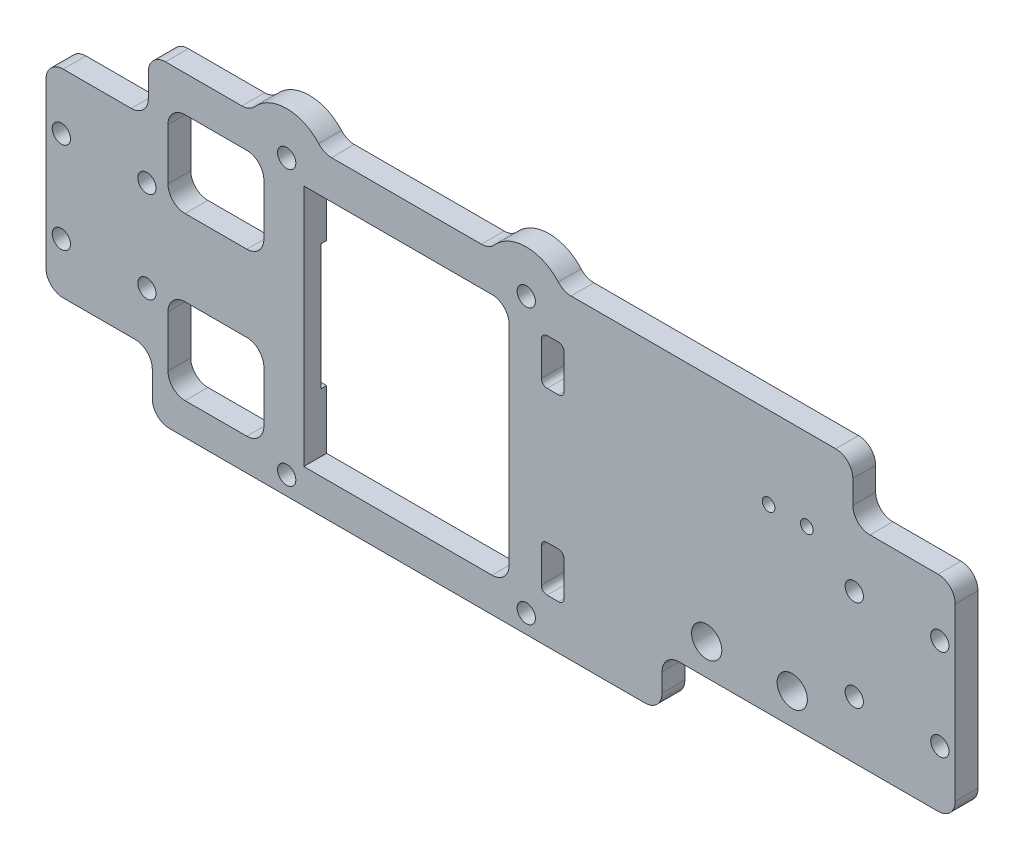
from build123d import *

# Parameters (mm, degrees)
SKETCH1_W                = 200
SKETCH1_H                = 135.733442348
SKETCH1_W_2              = 36
SKETCH1_H_2              = 42.1
BOSS_EXTRUDE1_DEPTH      = 4
M3_CLEARANCE_HOLE3_D     = 3.2
M3_CLEARANCE_HOLE3_DEPTH = 20
M3_CLEARANCE_HOLE3_TIP   = 0.96137699
M3_CLEARANCE_HOLE2_D     = 3.6
M3_CLEARANCE_HOLE2_DEPTH = 20
M3_CLEARANCE_HOLE2_TIP   = 1.081549114
ESBO_O16_W               = 16.814344546
ESBO_O16_H               = 12
RESSALTO_EXTRUS_O1_DEPTH = 4
FILETE2_R                = 1.5
ESBO_O10_W               = 1
ESBO_O10_H               = 4.177581522
CORTE_EXTRUS_O3_DEPTH    = 1
M5_CLEARANCE_HOLE1_D     = 5.3
ESBO_O13_OUTSIDE_W       = 250.348
ESBO_O13_OUTSIDE_H       = 186.081
CORTE_EXTRUS_O4_DEPTH    = 5
FILETE3_R                = 3
FILETE4_R                = 1.5
M3_CLEARANCE_HOLE5_D     = 3.2
M2_CLEARANCE_HOLE1_D     = 2.2
ESBO_O20_R               = 1.5
CORTE_EXTRUS_O5_DEPTH    = 10
M3_CLEARANCE_HOLE1_D     = 3.2
SKETCH53_W               = 36
SKETCH53_H               = 0.25
CUT_EXTRUDE12_DEPTH      = 10
SKETCH54_W               = 4
SKETCH54_H               = 8
CUT_EXTRUDE13_DEPTH      = 10
FILLET1_R                = 1
CUT_EXTRUDE14_DEPTH      = 10
SKETCH56_W               = 3.64947879
SKETCH56_H               = 22
CUT_EXTRUDE15_DEPTH      = 1
SKETCH57_R               = 2.05212086
CUT_EXTRUDE16_DEPTH      = 4
CUT_EXTRUDE17_DEPTH      = 4
SKETCH59_W               = 155.037210428
SKETCH59_H               = 70.505099338
CUT_EXTRUDE18_DEPTH      = 4
FILLET2_R                = 3
SKETCH60_W               = 18.240143326
SKETCH60_H               = 4.433631385
SKETCH60_H_2             = 1.833631385
BOSS_EXTRUDE2_DEPTH      = 4
FILLET3_R                = 3
FILETE5_R                = 3
SKETCH61_W               = 53.971209307
SKETCH61_H               = 36.749071907
SKETCH61_W_2             = 19.857566902
SKETCH61_H_2             = 38.368874149
CUT_EXTRUDE19_DEPTH      = 4
FILLET4_R                = 3
BOSS_EXTRUDE3_DEPTH      = 4
FILLET5_R                = 3


with BuildPart() as part:
    # Sketch1 → Boss-Extrude1 (new body)
    with BuildSketch(Plane.XY):
        with Locations((99.001292919, 88.116758365)):
            Rectangle(SKETCH1_W, SKETCH1_H)
        with BuildLine():
            Line((40.686948373, 33.880216301), (40.686948373, 79.280216301))
            ThreePointArc((40.686948373, 79.280216301), (41.272734811, 80.694429863), (42.686948373, 81.280216301))
            Line((42.686948373, 81.280216301), (55.501292919, 81.280216301))
            ThreePointArc((55.501292919, 81.280216301), (56.915506481, 80.694429863), (57.501292919, 79.280216301))
            Line((57.501292919, 79.280216301), (57.501292919, 33.880216301))
            ThreePointArc((57.501292919, 33.880216301), (56.915506481, 32.466002739), (55.501292919, 31.880216301))
            Line((55.501292919, 31.880216301), (42.686948373, 31.880216301))
            ThreePointArc((42.686948373, 31.880216301), (41.272734811, 32.466002739), (40.686948373, 33.880216301))
        make_face(mode=Mode.SUBTRACT)
        with Locations((82.501292919, 56.580216301)):
            Rectangle(SKETCH1_W_2, SKETCH1_H_2, mode=Mode.SUBTRACT)
    extrude(amount=BOSS_EXTRUDE1_DEPTH)

    # M3 Clearance Hole3
    with Locations(Plane(origin=(-2.189579835, 26.715952277, 4), x_dir=(1, 0, 0), z_dir=(0, 0, 1))):
        with Locations((63.690872753, 53.914264024), (63.690872753, 5.814264024), (105.690872753, 5.814264024), (105.690872753, 53.914264024)):
            Hole(M3_CLEARANCE_HOLE3_D / 2, depth=M3_CLEARANCE_HOLE3_DEPTH)
            with Locations((0, 0, -(M3_CLEARANCE_HOLE3_DEPTH + M3_CLEARANCE_HOLE3_TIP / 2))):  # 118° drill point
                Cone(0, M3_CLEARANCE_HOLE3_D / 2, M3_CLEARANCE_HOLE3_TIP, mode=Mode.SUBTRACT)

    # M3 Clearance Hole2
    with Locations(Plane.XY.offset(4)):
        with Locations((52.751292919, 139.766758365), (145.251292919, 139.766758365), (145.251292919, 86.466758365), (52.751292919, 86.466758365)):
            Hole(M3_CLEARANCE_HOLE2_D / 2, depth=M3_CLEARANCE_HOLE2_DEPTH)
            with Locations((0, 0, -(M3_CLEARANCE_HOLE2_DEPTH + M3_CLEARANCE_HOLE2_TIP / 2))):  # 118° drill point
                Cone(0, M3_CLEARANCE_HOLE2_D / 2, M3_CLEARANCE_HOLE2_TIP, mode=Mode.SUBTRACT)

    # Esbo_o16 → Ressalto-extrus_o1 (add)
    with BuildSketch(Plane.XY.offset(4)):
        with Locations((49.094120646, 56.580216301)):
            Rectangle(ESBO_O16_W, ESBO_O16_H)
    extrude(amount=-RESSALTO_EXTRUS_O1_DEPTH)

    # Filete2
    filete2_edges = [part.edges().sort_by_distance(p)[0] for p in [
        (-0.998707081, 155.983479539, 2),
        (199.001292919, 155.983479539, 2),
        (199.001292919, 20.250037191, 2),
        (-0.998707081, 20.250037191, 2),
    ]]
    fillet(filete2_edges, radius=FILETE2_R)

    # Esbo_o10 → Corte-extrus_o3 (cut)
    with BuildSketch(Plane(origin=(0, 0, 0), x_dir=(-1, 0, 0), z_dir=(0, 0, -1))):
        with Locations((-99.001292919, 155.983479539)):
            Rectangle(ESBO_O10_W, ESBO_O10_H)
    extrude(amount=-CORTE_EXTRUS_O3_DEPTH, mode=Mode.SUBTRACT)

    # M5 Clearance Hole1 (through all)
    with Locations(Plane(origin=(0, 0, 0), x_dir=(-1, 0, 0), z_dir=(0, 0, -1))):
        with Locations((-150.127125859, 44.005395411), (-135.127125859, 44.005395411)):
            Hole(M5_CLEARANCE_HOLE1_D / 2)

    # Esbo_o13 outside → Corte-extrus_o4 (cut, through all)
    with BuildSketch(Plane(origin=(0, 0, 0), x_dir=(-1, 0, 0), z_dir=(0, 0, -1))):
        with Locations((-99.001, 88.1165)):
            Rectangle(ESBO_O13_OUTSIDE_W, ESBO_O13_OUTSIDE_H)
        with BuildLine():
            Line((-179.691739081, 74.523312849), (-160.749455784, 74.523312849))
            Line((-160.749455784, 74.523312849), (-160.749455784, 105.180216331))
            ThreePointArc((-160.749455784, 105.180216331), (-168.249455784, 112.680216331), (-160.749455784, 120.180216331))
            Line((-160.749455784, 120.180216331), (-150.438183024, 134.349547733))
            ThreePointArc((-150.438183024, 134.349547733), (-151.315529823, 144.179810684), (-141.691903083, 146.368329693))
            Line((-141.691903083, 146.368329693), (-56.310682755, 146.368329693))
            ThreePointArc((-56.310682755, 146.368329693), (-46.687056014, 144.179810684), (-47.564402813, 134.349547733))
            Line((-47.564402813, 134.349547733), (-37.253130053, 120.180216331))
            ThreePointArc((-37.253130053, 120.180216331), (-29.753130053, 112.680216331), (-37.253130053, 105.180216331))
            Line((-37.253130053, 105.180216331), (-37.253130053, 74.523312849))
            Line((-37.253130053, 74.523312849), (-18.310846757, 74.523312849))
            Line((-18.310846757, 74.523312849), (-18.310846757, 29.275457367))
            Line((-18.310846757, 29.275457367), (-179.691739081, 29.275457367))
            Line((-179.691739081, 29.275457367), (-179.691739081, 74.523312849))
        make_face(mode=Mode.SUBTRACT)
    extrude(amount=-CORTE_EXTRUS_O4_DEPTH, mode=Mode.SUBTRACT)

    # Filete3
    filete3_edges = [part.edges().sort_by_distance(p)[0] for p in [
        (37.253130053, 74.523312849, 2),
        (18.310846757, 74.523312849, 2),
        (18.310846757, 29.275457367, 2),
        (179.691739081, 29.275457367, 2),
        (179.691739081, 74.523312849, 2),
        (160.749455784, 74.523312849, 2),
    ]]
    fillet(filete3_edges, radius=FILETE3_R)

    # Filete4
    filete4_edges = [part.edges().sort_by_distance(p)[0] for p in [
        (37.253130053, 105.180216331, 2),
        (160.749455784, 105.180216331, 2),
        (160.749455784, 120.180216331, 2),
        (150.438183024, 134.349547733, 2),
        (141.691903083, 146.368329693, 2),
        (56.310682755, 146.368329693, 2),
        (47.564402813, 134.349547733, 2),
        (37.253130053, 120.180216331, 2),
    ]]
    fillet(filete4_edges, radius=FILETE4_R)

    # M3 Clearance Hole5 (through all)
    with Locations(Plane(origin=(0, 0, 0), x_dir=(-1, 0, 0), z_dir=(0, 0, -1))):
        with Locations((-36.749455784, 112.680216331), (-160.749455784, 112.680216331)):
            Hole(M3_CLEARANCE_HOLE5_D / 2)

    # M2 Clearance Hole1 (through all)
    with Locations(Plane(origin=(0, 0, 0), x_dir=(-1, 0, 0), z_dir=(0, 0, -1))):
        with Locations((-145.982603611, 70.250037191), (-152.682603611, 70.250037191)):
            Hole(M2_CLEARANCE_HOLE1_D / 2)

    # Esbo_o20 → Corte-extrus_o5 (cut)
    with BuildSketch(Plane.XY.offset(4)):
        with Locations((99.001292919, 113.116758365)):
            Circle(ESBO_O20_R)
        with Locations((99.001292919, 119.116758365)):
            Circle(ESBO_O20_R)
        with Locations((95.144567261, 117.713025024)):
            Circle(ESBO_O20_R)
        with Locations((93.092446401, 114.158647431)):
            Circle(ESBO_O20_R)
        with Locations((93.805140496, 110.116758365)):
            Circle(ESBO_O20_R)
        with Locations((96.949172059, 107.478602641)):
            Circle(ESBO_O20_R)
        with Locations((101.053413779, 107.478602641)):
            Circle(ESBO_O20_R)
        with Locations((104.197445341, 110.116758365)):
            Circle(ESBO_O20_R)
        with Locations((104.910139437, 114.158647431)):
            Circle(ESBO_O20_R)
        with Locations((102.858018577, 117.713025024)):
            Circle(ESBO_O20_R)
        with Locations((99.001292919, 125.116758365)):
            Circle(ESBO_O20_R)
        with Locations((99.001292919, 131.116758365)):
            Circle(ESBO_O20_R)
        with Locations((99.001292919, 137.116758365)):
            Circle(ESBO_O20_R)
        with Locations((94.897051199, 124.393069815)):
            Circle(ESBO_O20_R)
        with Locations((91.287841602, 122.309291683)):
            Circle(ESBO_O20_R)
        with Locations((88.608988073, 119.116758365)):
            Circle(ESBO_O20_R)
        with Locations((87.183599882, 115.200536497)):
            Circle(ESBO_O20_R)
        with Locations((87.183599882, 111.032980233)):
            Circle(ESBO_O20_R)
        with Locations((88.608988073, 107.116758365)):
            Circle(ESBO_O20_R)
        with Locations((91.287841602, 103.924225048)):
            Circle(ESBO_O20_R)
        with Locations((94.897051199, 101.840446916)):
            Circle(ESBO_O20_R)
        with Locations((99.001292919, 101.116758365)):
            Circle(ESBO_O20_R)
        with Locations((103.105534639, 101.840446916)):
            Circle(ESBO_O20_R)
        with Locations((106.714744235, 103.924225048)):
            Circle(ESBO_O20_R)
        with Locations((109.393597764, 107.116758365)):
            Circle(ESBO_O20_R)
        with Locations((110.818985955, 111.032980233)):
            Circle(ESBO_O20_R)
        with Locations((110.818985955, 115.200536497)):
            Circle(ESBO_O20_R)
        with Locations((109.393597764, 119.116758365)):
            Circle(ESBO_O20_R)
        with Locations((106.714744235, 122.309291683)):
            Circle(ESBO_O20_R)
        with Locations((103.105534639, 124.393069815)):
            Circle(ESBO_O20_R)
        with Locations((102.743703353, 130.723415178)):
            Circle(ESBO_O20_R)
        with Locations((106.322552494, 129.560576603)):
            Circle(ESBO_O20_R)
        with Locations((109.58142746, 127.679064264)):
            Circle(ESBO_O20_R)
        with Locations((112.377899777, 125.16110928)):
            Circle(ESBO_O20_R)
        with Locations((114.589750187, 122.116758365)):
            Circle(ESBO_O20_R)
        with Locations((116.120310212, 118.679064264)):
            Circle(ESBO_O20_R)
        with Locations((116.902687035, 114.998270704)):
            Circle(ESBO_O20_R)
        with Locations((116.902687035, 111.235246026)):
            Circle(ESBO_O20_R)
        with Locations((116.120310212, 107.554452467)):
            Circle(ESBO_O20_R)
        with Locations((114.589750187, 104.116758365)):
            Circle(ESBO_O20_R)
        with Locations((112.377899777, 101.072407451)):
            Circle(ESBO_O20_R)
        with Locations((109.58142746, 98.554452467)):
            Circle(ESBO_O20_R)
        with Locations((106.322552494, 96.672940128)):
            Circle(ESBO_O20_R)
        with Locations((102.743703353, 95.510101552)):
            Circle(ESBO_O20_R)
        with Locations((99.001292919, 95.116758365)):
            Circle(ESBO_O20_R)
        with Locations((95.258882484, 95.510101552)):
            Circle(ESBO_O20_R)
        with Locations((91.680033343, 96.672940128)):
            Circle(ESBO_O20_R)
        with Locations((88.421158377, 98.554452467)):
            Circle(ESBO_O20_R)
        with Locations((85.62468606, 101.072407451)):
            Circle(ESBO_O20_R)
        with Locations((83.412835651, 104.116758365)):
            Circle(ESBO_O20_R)
        with Locations((81.882275625, 107.554452467)):
            Circle(ESBO_O20_R)
        with Locations((81.099898802, 111.235246026)):
            Circle(ESBO_O20_R)
        with Locations((81.099898802, 114.998270704)):
            Circle(ESBO_O20_R)
        with Locations((81.882275625, 118.679064264)):
            Circle(ESBO_O20_R)
        with Locations((83.412835651, 122.116758365)):
            Circle(ESBO_O20_R)
        with Locations((85.62468606, 125.16110928)):
            Circle(ESBO_O20_R)
        with Locations((88.421158377, 127.679064264)):
            Circle(ESBO_O20_R)
        with Locations((91.680033343, 129.560576603)):
            Circle(ESBO_O20_R)
        with Locations((95.258882484, 130.723415178)):
            Circle(ESBO_O20_R)
        with Locations((103.411281346, 136.708112758)):
            Circle(ESBO_O20_R)
        with Locations((107.671092907, 135.496091871)):
            Circle(ESBO_O20_R)
        with Locations((111.635664828, 133.521969623)):
            Circle(ESBO_O20_R)
        with Locations((115.169988366, 130.852972379)):
            Circle(ESBO_O20_R)
        with Locations((118.153706373, 127.579989638)):
            Circle(ESBO_O20_R)
        with Locations((120.485211911, 123.814478904)):
            Circle(ESBO_O20_R)
        with Locations((122.085108355, 119.684670127)):
            Circle(ESBO_O20_R)
        with Locations((122.89891315, 115.331198992)):
            Circle(ESBO_O20_R)
        with Locations((122.89891315, 110.902317738)):
            Circle(ESBO_O20_R)
        with Locations((122.085108355, 106.548846604)):
            Circle(ESBO_O20_R)
        with Locations((120.485211911, 102.419037827)):
            Circle(ESBO_O20_R)
        with Locations((118.153706373, 98.653527092)):
            Circle(ESBO_O20_R)
        with Locations((115.169988366, 95.380544352)):
            Circle(ESBO_O20_R)
        with Locations((111.635664828, 92.711547108)):
            Circle(ESBO_O20_R)
        with Locations((107.671092907, 90.73742486)):
            Circle(ESBO_O20_R)
        with Locations((103.411281346, 89.525403973)):
            Circle(ESBO_O20_R)
        with Locations((99.001292919, 89.116758365)):
            Circle(ESBO_O20_R)
        with Locations((94.591304491, 89.525403973)):
            Circle(ESBO_O20_R)
        with Locations((90.33149293, 90.73742486)):
            Circle(ESBO_O20_R)
        with Locations((86.36692101, 92.711547108)):
            Circle(ESBO_O20_R)
        with Locations((82.832597471, 95.380544352)):
            Circle(ESBO_O20_R)
        with Locations((79.848879464, 98.653527092)):
            Circle(ESBO_O20_R)
        with Locations((77.517373926, 102.419037827)):
            Circle(ESBO_O20_R)
        with Locations((75.917477482, 106.548846604)):
            Circle(ESBO_O20_R)
        with Locations((75.103672688, 110.902317738)):
            Circle(ESBO_O20_R)
        with Locations((75.103672688, 115.331198992)):
            Circle(ESBO_O20_R)
        with Locations((75.917477482, 119.684670127)):
            Circle(ESBO_O20_R)
        with Locations((77.517373926, 123.814478904)):
            Circle(ESBO_O20_R)
        with Locations((79.848879464, 127.579989638)):
            Circle(ESBO_O20_R)
        with Locations((82.832597471, 130.852972379)):
            Circle(ESBO_O20_R)
        with Locations((86.36692101, 133.521969623)):
            Circle(ESBO_O20_R)
        with Locations((90.33149293, 135.496091871)):
            Circle(ESBO_O20_R)
        with Locations((94.591304491, 136.708112758)):
            Circle(ESBO_O20_R)
    extrude(amount=-CORTE_EXTRUS_O5_DEPTH, mode=Mode.SUBTRACT)

    # M3 Clearance Hole1 (through all)
    with Locations(Plane(origin=(0, 0, 0), x_dir=(-1, 0, 0), z_dir=(0, 0, -1))):
        with Locations((-161.000846757, 64.580216301), (-176.000846757, 64.580216301), (-176.000846757, 48.580216301), (-161.000846757, 48.580216301), (-22.000846757, 64.580216301), (-37.000846757, 64.580216301), (-37.000846757, 48.580216301), (-22.000846757, 48.580216301)):
            Hole(M3_CLEARANCE_HOLE1_D / 2)

    # Sketch53 → Cut-Extrude12 (cut)
    with BuildSketch(Plane(origin=(0, 0, 0), x_dir=(-1, 0, 0), z_dir=(0, 0, -1))):
        with Locations((-82.501292919, 77.755216301)):
            Rectangle(SKETCH53_W, SKETCH53_H)
        with Locations((-82.501292919, 35.405216301)):
            Rectangle(SKETCH53_W, SKETCH53_H)
    extrude(amount=-CUT_EXTRUDE12_DEPTH, mode=Mode.SUBTRACT)

    # Sketch54 → Cut-Extrude13 (cut)
    with BuildSketch(Plane.XY.offset(4)):
        with Locations((108.14129292, 72.484085576)):
            Rectangle(SKETCH54_W, SKETCH54_H)
        with Locations((108.14129292, 41.080216301)):
            Rectangle(SKETCH54_W, SKETCH54_H)
    extrude(amount=-CUT_EXTRUDE13_DEPTH, mode=Mode.SUBTRACT)

    # Fillet1
    fillet1_edges = [part.edges().sort_by_distance(p)[0] for p in [
        (106.14129292, 68.484085576, 2),
        (106.14129292, 76.484085576, 2),
        (110.14129292, 76.484085576, 2),
        (110.14129292, 68.484085576, 2),
        (106.14129292, 37.080216301, 2),
        (106.14129292, 45.080216301, 2),
        (110.14129292, 45.080216301, 2),
        (110.14129292, 37.080216301, 2),
    ]]
    fillet(fillet1_edges, radius=FILLET1_R)

    # Sketch55 → Cut-Extrude14 (cut)
    with BuildSketch(Plane.XY.offset(4)):
        with BuildLine():
            Line((34.253130053, 74.523312849), (34.253130053, 83.266670956))
            Line((34.253130053, 83.266670956), (6.596065841, 83.266670956))
            Line((6.596065841, 83.266670956), (6.596065841, 19.300903913))
            Line((6.596065841, 19.300903913), (195.367640133, 19.300903913))
            Line((195.367640133, 19.300903913), (195.367640133, 88.625059818))
            Line((195.367640133, 88.625059818), (163.749455784, 88.625059818))
            Line((163.749455784, 88.625059818), (163.749455784, 74.523312849))
            Line((163.749455784, 74.523312849), (175.691739081, 74.523312849))
            ThreePointArc((175.691739081, 74.523312849), (177.813059424, 73.644633192), (178.691739081, 71.523312849))
            Line((178.691739081, 71.523312849), (178.691739081, 29.697784481))
            ThreePointArc((178.691739081, 29.697784481), (177.813059424, 27.576464138), (175.691739081, 26.697784481))
            Line((175.691739081, 26.697784481), (22.310846757, 26.697784481))
            ThreePointArc((22.310846757, 26.697784481), (20.189526413, 27.576464138), (19.310846757, 29.697784481))
            Line((19.310846757, 29.697784481), (19.310846757, 71.523312849))
            ThreePointArc((19.310846757, 71.523312849), (20.189526413, 73.644633192), (22.310846757, 74.523312849))
            Line((22.310846757, 74.523312849), (34.253130053, 74.523312849))
        make_face()
    extrude(amount=-CUT_EXTRUDE14_DEPTH, mode=Mode.SUBTRACT)

    # Sketch56 → Cut-Extrude15 (cut)
    with BuildSketch(Plane(origin=(0, 0, 0), x_dir=(-1, 0, 0), z_dir=(0, 0, -1))):
        with Locations((-62.676553524, 56.580216301)):
            Rectangle(SKETCH56_W, SKETCH56_H)
    extrude(amount=-CUT_EXTRUDE15_DEPTH, mode=Mode.SUBTRACT)

    # Sketch57 → Cut-Extrude16 (cut)
    with BuildSketch(Plane.XY.offset(4)):
        with Locations((99.001292919, 113.116758365)):
            Circle(SKETCH57_R)
        with BuildLine():
            ThreePointArc((108.212955406, 136.894800215), (99.001292919, 138.616758365), (89.789630431, 136.894800215))
            ThreePointArc((89.789630431, 136.894800215), (88.932784586, 134.954229372), (90.873355429, 134.097383527))
            ThreePointArc((90.873355429, 134.097383527), (99.001292919, 135.616758365), (107.129230408, 134.097383527))
            ThreePointArc((107.129230408, 134.097383527), (109.069801251, 134.954229372), (108.212955406, 136.894800215))
        make_face()
        with BuildLine():
            ThreePointArc((106.932692872, 130.930879022), (99.001292919, 132.616857242), (91.069892966, 130.930879022))
            ThreePointArc((91.069892966, 130.930879022), (90.309730924, 128.950436225), (92.290173721, 128.190274184))
            ThreePointArc((92.290173721, 128.190274184), (99.001292919, 129.616857242), (105.712412116, 128.190274184))
            ThreePointArc((105.712412116, 128.190274184), (107.692854913, 128.950436225), (106.932692872, 130.930879022))
        make_face()
        with BuildLine():
            ThreePointArc((107.678925649, 123.458358347), (99.001292919, 126.616758365), (90.323660188, 123.458358347))
            ThreePointArc((90.323660188, 123.458358347), (90.138774938, 121.345110268), (92.252023017, 121.160225018))
            ThreePointArc((92.252023017, 121.160225018), (99.001292919, 123.616758365), (105.75056282, 121.160225018))
            ThreePointArc((105.75056282, 121.160225018), (107.8638109, 121.345110268), (107.678925649, 123.458358347))
        make_face()
        with BuildLine():
            ThreePointArc((106.387351066, 114.419119698), (99.001292919, 120.616758365), (91.615234771, 114.419119698))
            ThreePointArc((91.615234771, 114.419119698), (92.831974134, 112.681435802), (94.56965803, 113.898175165))
            ThreePointArc((94.56965803, 113.898175165), (99.001292919, 117.616758365), (103.432927807, 113.898175165))
            ThreePointArc((103.432927807, 113.898175165), (105.170611703, 112.681435802), (106.387351066, 114.419119698))
        make_face()
        with BuildLine():
            ThreePointArc((124.199512457, 117.028245565), (121.084940715, 125.866758365), (114.987849969, 132.983313016))
            ThreePointArc((114.987849969, 132.983313016), (112.878843398, 132.755077863), (113.107078551, 130.646071292))
            ThreePointArc((113.107078551, 130.646071292), (118.486864504, 124.366758365), (121.23501604, 116.5680706))
            ThreePointArc((121.23501604, 116.5680706), (122.947351731, 115.315909874), (124.199512457, 117.028245565))
        make_face()
        with BuildLine():
            ThreePointArc((114.987849969, 93.250203715), (121.084940715, 100.366758365), (124.199512457, 109.205271166))
            ThreePointArc((124.199512457, 109.205271166), (122.947351731, 110.917606856), (121.23501604, 109.66544613))
            ThreePointArc((121.23501604, 109.66544613), (118.486864504, 101.866758365), (113.107078551, 95.587445438))
            ThreePointArc((113.107078551, 95.587445438), (112.878843398, 93.478438868), (114.987849969, 93.250203715))
        make_face()
        with BuildLine():
            ThreePointArc((89.789630431, 89.338716515), (99.001292919, 87.616758365), (108.212955406, 89.338716515))
            ThreePointArc((108.212955406, 89.338716515), (109.069801251, 91.279287359), (107.129230408, 92.136133204))
            ThreePointArc((107.129230408, 92.136133204), (99.001292919, 90.616758365), (90.873355429, 92.136133204))
            ThreePointArc((90.873355429, 92.136133204), (88.932784586, 91.279287359), (89.789630431, 89.338716515))
        make_face()
        with BuildLine():
            ThreePointArc((73.803073381, 109.205271166), (76.917645122, 100.366758365), (83.014735868, 93.250203715))
            ThreePointArc((83.014735868, 93.250203715), (85.123742439, 93.478438868), (84.895507286, 95.587445438))
            ThreePointArc((84.895507286, 95.587445438), (79.515721333, 101.866758365), (76.767569797, 109.66544613))
            ThreePointArc((76.767569797, 109.66544613), (75.055234106, 110.917606856), (73.803073381, 109.205271166))
        make_face()
        with BuildLine():
            ThreePointArc((83.014735868, 132.983313016), (76.917645122, 125.866758365), (73.803073381, 117.028245565))
            ThreePointArc((73.803073381, 117.028245565), (75.055234106, 115.315909874), (76.767569797, 116.5680706))
            ThreePointArc((76.767569797, 116.5680706), (79.515721333, 124.366758365), (84.895507286, 130.646071292))
            ThreePointArc((84.895507286, 130.646071292), (85.123742439, 132.755077863), (83.014735868, 132.983313016))
        make_face()
        with BuildLine():
            ThreePointArc((118.393483533, 115.155596653), (115.887883525, 122.867379609), (110.46208358, 128.893184346))
            ThreePointArc((110.46208358, 128.893184346), (108.366888787, 128.561282587), (108.698790546, 126.466087793))
            ThreePointArc((108.698790546, 126.466087793), (113.289807314, 121.367379609), (115.409909744, 114.842088367))
            ThreePointArc((115.409909744, 114.842088367), (117.058450781, 113.507055615), (118.393483533, 115.155596653))
        make_face()
        with BuildLine():
            ThreePointArc((110.46208358, 97.342619608), (115.887883525, 103.368424345), (118.393483533, 111.080207302))
            ThreePointArc((118.393483533, 111.080207302), (117.058450781, 112.728748339), (115.409909744, 111.393715587))
            ThreePointArc((115.409909744, 111.393715587), (113.289807314, 104.868424345), (108.698790546, 99.769716161))
            ThreePointArc((108.698790546, 99.769716161), (108.366888787, 97.674521367), (110.46208358, 97.342619608))
        make_face()
        with BuildLine():
            ThreePointArc((91.069892966, 95.304924932), (99.001292919, 93.618946712), (106.932692872, 95.304924932))
            ThreePointArc((106.932692872, 95.304924932), (107.692854913, 97.285367729), (105.712412116, 98.04552977))
            ThreePointArc((105.712412116, 98.04552977), (99.001292919, 96.618946712), (92.290173721, 98.04552977))
            ThreePointArc((92.290173721, 98.04552977), (90.309730924, 97.285367729), (91.069892966, 95.304924932))
        make_face()
        with BuildLine():
            ThreePointArc((79.609102304, 111.080207302), (82.114702312, 103.368424345), (87.540502257, 97.342619608))
            ThreePointArc((87.540502257, 97.342619608), (89.635697051, 97.674521367), (89.303795291, 99.769716161))
            ThreePointArc((89.303795291, 99.769716161), (84.712778524, 104.868424345), (82.592676093, 111.393715587))
            ThreePointArc((82.592676093, 111.393715587), (80.944135056, 112.728748339), (79.609102304, 111.080207302))
        make_face()
        with BuildLine():
            ThreePointArc((87.540502257, 128.893184346), (82.114702312, 122.867379609), (79.609102304, 115.155596653))
            ThreePointArc((79.609102304, 115.155596653), (80.944135056, 113.507055615), (82.592676093, 114.842088367))
            ThreePointArc((82.592676093, 114.842088367), (84.712778524, 121.367379609), (89.303795291, 126.466087793))
            ThreePointArc((89.303795291, 126.466087793), (89.635697051, 128.561282587), (87.540502257, 128.893184346))
        make_face()
        with BuildLine():
            ThreePointArc((103.618564854, 100.430907985), (110.69263587, 106.366758365), (112.296197584, 115.461008764))
            ThreePointArc((112.296197584, 115.461008764), (110.558513688, 116.677748127), (109.341774325, 114.940064231))
            ThreePointArc((109.341774325, 114.940064231), (108.094559658, 107.866758365), (102.592504424, 103.249985847))
            ThreePointArc((102.592504424, 103.249985847), (101.695995707, 101.327416701), (103.618564854, 100.430907985))
        make_face()
        with BuildLine():
            ThreePointArc((85.706388253, 115.461008764), (87.309949968, 106.366758365), (94.384020984, 100.430907985))
            ThreePointArc((94.384020984, 100.430907985), (96.30659013, 101.327416701), (95.410081414, 103.249985847))
            ThreePointArc((95.410081414, 103.249985847), (89.908026179, 107.866758365), (88.660811512, 114.940064231))
            ThreePointArc((88.660811512, 114.940064231), (87.444072149, 116.677748127), (85.706388253, 115.461008764))
        make_face()
        with BuildLine():
            ThreePointArc((92.506226196, 109.366543969), (99.001292919, 105.617330089), (105.496359642, 109.366543969))
            ThreePointArc((105.496359642, 109.366543969), (104.947659738, 111.415672665), (102.898531041, 110.866972762))
            ThreePointArc((102.898531041, 110.866972762), (99.001292919, 108.617330089), (95.104054796, 110.866972762))
            ThreePointArc((95.104054796, 110.866972762), (93.054926099, 111.415672665), (92.506226196, 109.366543969))
        make_face()
    extrude(amount=-CUT_EXTRUDE16_DEPTH, mode=Mode.SUBTRACT)

    # Sketch58 → Cut-Extrude17 (cut)
    with BuildSketch(Plane.XY.offset(4)):
        with BuildLine():
            ThreePointArc((73.610071423, 110.763915199), (77.320755958, 99.692738212), (85.577272765, 91.436221404))
            ThreePointArc((85.577272765, 91.436221404), (87.642246713, 91.921898863), (87.156569254, 93.986872811))
            ThreePointArc((87.156569254, 93.986872811), (79.871407365, 101.272034701), (76.597273952, 111.040720277))
            ThreePointArc((76.597273952, 111.040720277), (74.965270148, 112.395919003), (73.610071423, 110.763915199))
        make_face()
        with BuildLine():
            ThreePointArc((85.577437362, 134.79739724), (77.320857872, 126.540943115), (73.610089286, 115.469794299))
            ThreePointArc((73.610089286, 115.469794299), (74.965275622, 113.837780207), (76.597289714, 115.192966542))
            ThreePointArc((76.597289714, 115.192966542), (79.871497289, 124.961627262), (87.156714487, 132.246733843))
            ThreePointArc((87.156714487, 132.246733843), (87.642407623, 134.311704103), (85.577437362, 134.79739724))
        make_face()
        with BuildLine():
            ThreePointArc((124.39253884, 115.469337685), (124.392526633, 115.469469609), (124.392514414, 115.469601532))
            ThreePointArc((124.392514414, 115.469601532), (120.68182988, 126.540778519), (112.425313072, 134.797295326))
            ThreePointArc((112.425313072, 134.797295326), (111.636675947, 135.021969282), (110.847736642, 134.798358738))
            ThreePointArc((110.847736642, 134.798358738), (110.138878585, 133.523212845), (110.849004881, 132.248772797))
            ThreePointArc((110.849004881, 132.248772797), (118.132879734, 124.962324099), (121.40528746, 115.1930603))
            ThreePointArc((121.405287435, 115.193060297), (121.405299661, 115.192928375), (121.405311885, 115.192796453))
            ThreePointArc((121.405311885, 115.192796453), (123.037183766, 113.837585509), (124.39253884, 115.469337685))
        make_face()
        with BuildLine():
            ThreePointArc((112.424923176, 91.435980021), (120.682961038, 99.690975494), (124.395685282, 110.76146863))
            ThreePointArc((124.395685282, 110.76146863), (123.040787263, 112.39372209), (121.408533803, 111.038824071))
            ThreePointArc((121.408533803, 111.038824071), (118.132600646, 101.270741892), (110.84609665, 93.986922357))
            ThreePointArc((110.84609665, 93.986922357), (110.360038745, 91.922037927), (112.424923176, 91.435980021))
        make_face()
    extrude(amount=-CUT_EXTRUDE17_DEPTH, mode=Mode.SUBTRACT)

    # Sketch59 → Cut-Extrude18 (cut)
    with BuildSketch(Plane.XY.offset(4)):
        with Locations((102.960704754, 119.851521831)):
            Rectangle(SKETCH59_W, SKETCH59_H)
    extrude(amount=-CUT_EXTRUDE18_DEPTH, mode=Mode.SUBTRACT)

    # Fillet2
    fillet2_edges = [part.edges().sort_by_distance(p)[0] for p in [
        (160.749455784, 84.598972162, 2),
        (37.253130053, 84.598972162, 2),
    ]]
    fillet(fillet2_edges, radius=FILLET2_R)

    # Sketch60 → Boss-Extrude2 (add)
    with BuildSketch(Plane(origin=(0, 0, 0), x_dir=(-1, 0, 0), z_dir=(0, 0, -1))):
        with Locations((-49.077783293, 80.497031994)):
            Rectangle(SKETCH60_W, SKETCH60_H)
        with Locations((-49.077783293, 62.363400609)):
            Rectangle(SKETCH60_W, SKETCH60_H_2)
        with Locations((-49.077783293, 50.797031993)):
            Rectangle(SKETCH60_W, SKETCH60_H_2)
        with Locations((-49.077783293, 32.663400609)):
            Rectangle(SKETCH60_W, SKETCH60_H)
    extrude(amount=-BOSS_EXTRUDE2_DEPTH)

    # Fillet3
    fillet3_edges = [part.edges().sort_by_distance(p)[0] for p in [
        (40.686948373, 78.280216301, 2),
        (57.501292919, 78.280216301, 2),
        (57.501292919, 34.880216301, 2),
        (40.686948373, 34.880216301, 2),
    ]]
    fillet(fillet3_edges, radius=FILLET3_R)

    # Filete5
    filete5_edges = [part.edges().sort_by_distance(p)[0] for p in [
        (57.501292919, 63.280216301, 2),
        (40.686948373, 63.280216301, 2),
        (40.686948373, 49.880216301, 2),
        (57.501292919, 49.880216301, 2),
        (100.501292919, 77.880216301, 2),
        (100.501292919, 35.280216301, 2),
    ]]
    fillet(filete5_edges, radius=FILETE5_R)

    # Sketch61 → Cut-Extrude19 (cut)
    with BuildSketch(Plane(origin=(0, 0, 0), x_dir=(-1, 0, 0), z_dir=(0, 0, -1))):
        with Locations((-154.290027917, 20.145165351)):
            Rectangle(SKETCH61_W, SKETCH61_H)
        with Locations((-28.012452174, 20.60580778)):
            Rectangle(SKETCH61_W_2, SKETCH61_H_2)
    extrude(amount=-CUT_EXTRUDE19_DEPTH, mode=Mode.SUBTRACT)

    # Fillet4
    fillet4_edges = [part.edges().sort_by_distance(p)[0] for p in [
        (178.691739081, 38.519701304, 2),
        (127.304423263, 29.275457367, 2),
        (127.304423263, 38.519701304, 2),
        (19.310846757, 39.790244854, 2),
        (37.941235625, 29.275457367, 2),
        (37.941235625, 39.790244854, 2),
    ]]
    fillet(fillet4_edges, radius=FILLET4_R)

    # Sketch62 → Boss-Extrude3 (add)
    with BuildSketch(Plane.XY.offset(4)):
        with BuildLine():
            Line((55.13741227, 84.598972162), (67.865173568, 84.598972162))
            ThreePointArc((67.865173568, 84.598972162), (61.501292919, 88.130216301), (55.13741227, 84.598972162))
        make_face()
        with BuildLine():
            Line((97.13741227, 84.598972162), (109.865173568, 84.598972162))
            ThreePointArc((109.865173568, 84.598972162), (103.501292919, 88.130216301), (97.13741227, 84.598972162))
        make_face()
    extrude(amount=-BOSS_EXTRUDE3_DEPTH)

    # Fillet5
    fillet5_edges = [part.edges().sort_by_distance(p)[0] for p in [
        (55.13741227, 84.598972162, 2),
        (67.865173568, 84.598972162, 2),
        (97.13741227, 84.598972162, 2),
        (109.865173568, 84.598972162, 2),
    ]]
    fillet(fillet5_edges, radius=FILLET5_R)


solid = part.part
